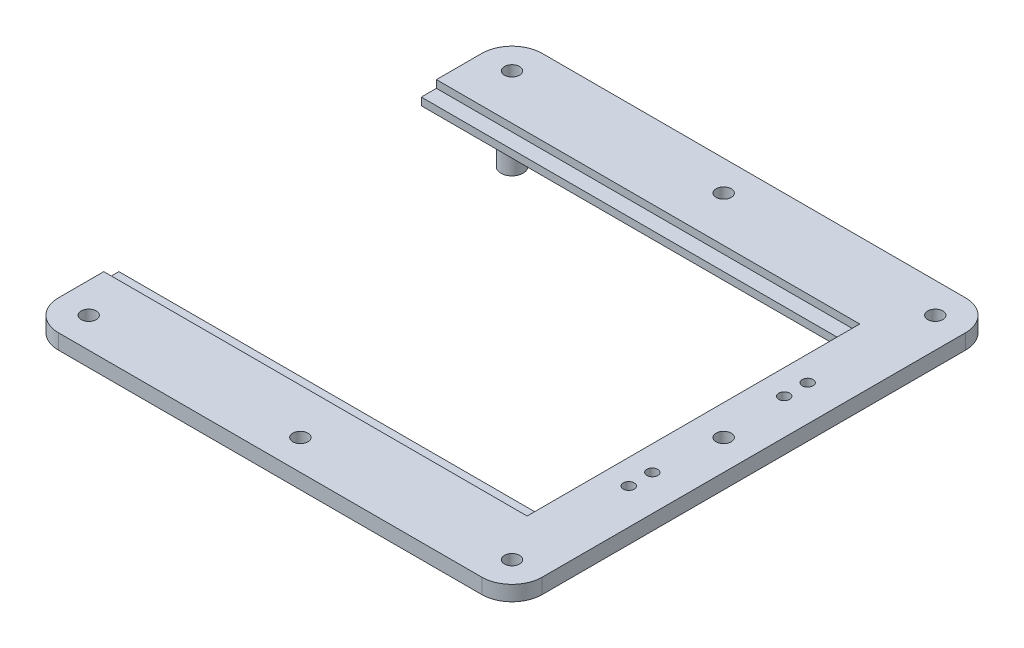
from build123d import *

# Parameters (mm, degrees)
BOSS_EXTRUDE2_DEPTH = 6.35
SKETCH2_R           = 3.175
CUT_EXTRUDE1_DEPTH  = 7.35
SKETCH5_R           = 4.6625
BOSS_EXTRUDE3_DEPTH = 12.7
SKETCH6_W           = 177.8
SKETCH6_H           = 6.35
CUT_EXTRUDE2_DEPTH  = 3.175
SKETCH7_R           = 2.286
CUT_EXTRUDE3_DEPTH  = 12.7
SKETCH8_R           = 3.175
CUT_EXTRUDE4_DEPTH  = 20.05


with BuildPart() as part:
    # Sketch1 → Boss-Extrude2 (new body)
    with BuildSketch(Plane(origin=(0, 0, 0), x_dir=(1, 0, 0), z_dir=(0, 1, 0))):
        with BuildLine():
            Line((0, 0), (0, 25.4))
            ThreePointArc((0, 25.4), (3.719743879, 34.380256121), (12.7, 38.1))
            Line((12.7, 38.1), (190.5, 38.1))
            ThreePointArc((190.5, 38.1), (199.480256121, 34.380256121), (203.2, 25.4))
            Line((203.2, 25.4), (203.2, -152.4))
            ThreePointArc((203.2, -152.4), (199.480256121, -161.380256121), (190.5, -165.1))
            Line((190.5, -165.1), (12.7, -165.1))
            ThreePointArc((12.7, -165.1), (3.719743879, -161.380256121), (0, -152.4))
            Line((0, -152.4), (0, -127))
            Line((0, -127), (177.8, -127))
            Line((177.8, -127), (177.8, 0))
            Line((177.8, 0), (0, 0))
        make_face()
    extrude(amount=BOSS_EXTRUDE2_DEPTH)

    # Sketch2 → Cut-Extrude1 (cut, through all)
    with BuildSketch(Plane(origin=(0, 6.35, 0), x_dir=(1, 0, 0), z_dir=(0, 1, 0))):
        with Locations((12.7, 25.4)):
            Circle(SKETCH2_R)
        with Locations((190.5, 25.4)):
            Circle(SKETCH2_R)
        with Locations((190.5, -152.4)):
            Circle(SKETCH2_R)
        with Locations((12.7, -152.4)):
            Circle(SKETCH2_R)
    extrude(amount=-CUT_EXTRUDE1_DEPTH, mode=Mode.SUBTRACT)

    # Sketch5 → Boss-Extrude3 (add)
    with BuildSketch(Plane.XZ):
        with Locations((28.575, 136.525)):
            Circle(SKETCH5_R)
        with Locations((174.625, 136.525)):
            Circle(SKETCH5_R)
        with Locations((174.625, -9.525)):
            Circle(SKETCH5_R)
        with Locations((28.575, -9.525)):
            Circle(SKETCH5_R)
    extrude(amount=BOSS_EXTRUDE3_DEPTH)

    # Sketch6 → Cut-Extrude2 (cut)
    with BuildSketch(Plane(origin=(0, 6.35, 0), x_dir=(1, 0, 0), z_dir=(0, 1, 0))):
        with Locations((88.9, -130.175)):
            Rectangle(SKETCH6_W, SKETCH6_H)
        with Locations((88.9, 3.175)):
            Rectangle(SKETCH6_W, SKETCH6_H)
    extrude(amount=-CUT_EXTRUDE2_DEPTH, mode=Mode.SUBTRACT)

    # Sketch7 → Cut-Extrude3 (cut)
    with BuildSketch(Plane(origin=(0, 6.35, 0), x_dir=(1, 0, 0), z_dir=(0, 1, 0))):
        with Locations((188.214, -101.092)):
            Circle(SKETCH7_R)
        with Locations((188.214, -91.186)):
            Circle(SKETCH7_R)
        with Locations((188.214, -35.814)):
            Circle(SKETCH7_R)
        with Locations((188.214, -25.908)):
            Circle(SKETCH7_R)
    extrude(amount=-CUT_EXTRUDE3_DEPTH, mode=Mode.SUBTRACT)

    # Sketch8 → Cut-Extrude4 (cut, through all)
    with BuildSketch(Plane(origin=(0, 6.35, 0), x_dir=(1, 0, 0), z_dir=(0, 1, 0))):
        with Locations((101.6, 25.4)):
            Circle(SKETCH8_R)
        with Locations((190.5, -63.5)):
            Circle(SKETCH8_R)
        with Locations((101.6, -152.4)):
            Circle(SKETCH8_R)
    extrude(amount=-CUT_EXTRUDE4_DEPTH, mode=Mode.SUBTRACT)


solid = part.part
